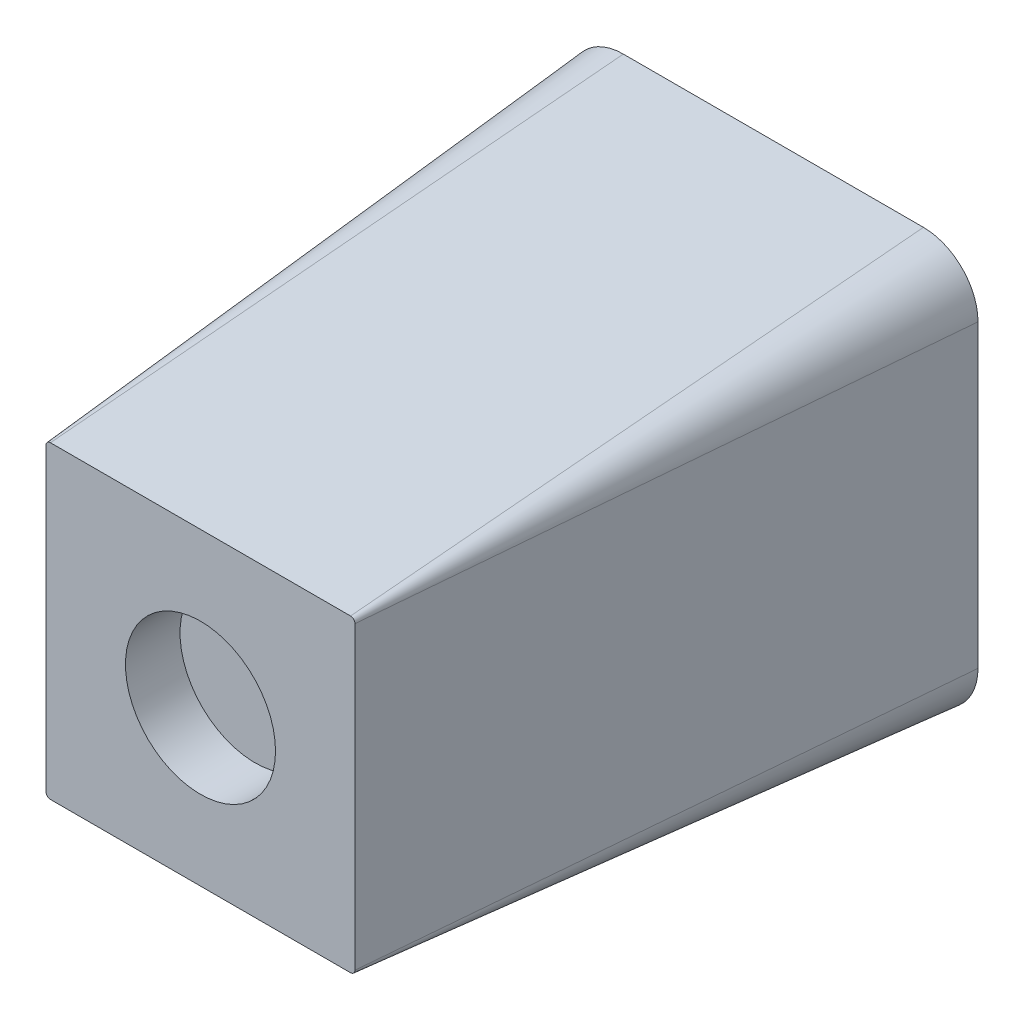
from build123d import *

# Parameters (mm, degrees)
BOSS_EXTRUDE1_DEPTH = 21
BOSS_EXTRUDE1_TAPER = 5
SKETCH2_R           = 1.5
CUT_EXTRUDE1_DEPTH  = 10
SKETCH3_R           = 2.75
CUT_EXTRUDE2_DEPTH  = 2


with BuildPart() as part:
    # Sketch1 → Boss-Extrude1 (new body)
    with BuildSketch(Plane.XY):
        with BuildLine():
            Line((-5.5, -7.5), (5.5, -7.5))
            ThreePointArc((5.5, -7.5), (6.914213562, -6.914213562), (7.5, -5.5))
            Line((7.5, -5.5), (7.5, 5.5))
            ThreePointArc((7.5, 5.5), (6.914213562, 6.914213562), (5.5, 7.5))
            Line((5.5, 7.5), (-5.5, 7.5))
            ThreePointArc((-5.5, 7.5), (-6.914213562, 6.914213562), (-7.5, 5.5))
            Line((-7.5, 5.5), (-7.5, -5.5))
            ThreePointArc((-7.5, -5.5), (-6.914213562, -6.914213562), (-5.5, -7.5))
        make_face()
    extrude(amount=BOSS_EXTRUDE1_DEPTH, taper=BOSS_EXTRUDE1_TAPER)

    # Sketch2 → Cut-Extrude1 (cut)
    with BuildSketch(Plane(origin=(0, 0, 0), x_dir=(-1, 0, 0), z_dir=(0, 0, -1))):
        Circle(SKETCH2_R)
    extrude(amount=-CUT_EXTRUDE1_DEPTH, mode=Mode.SUBTRACT)

    # Sketch3 → Cut-Extrude2 (cut)
    with BuildSketch(Plane.XY.offset(21)):
        Circle(SKETCH3_R)
    extrude(amount=-CUT_EXTRUDE2_DEPTH, mode=Mode.SUBTRACT)


solid = part.part
